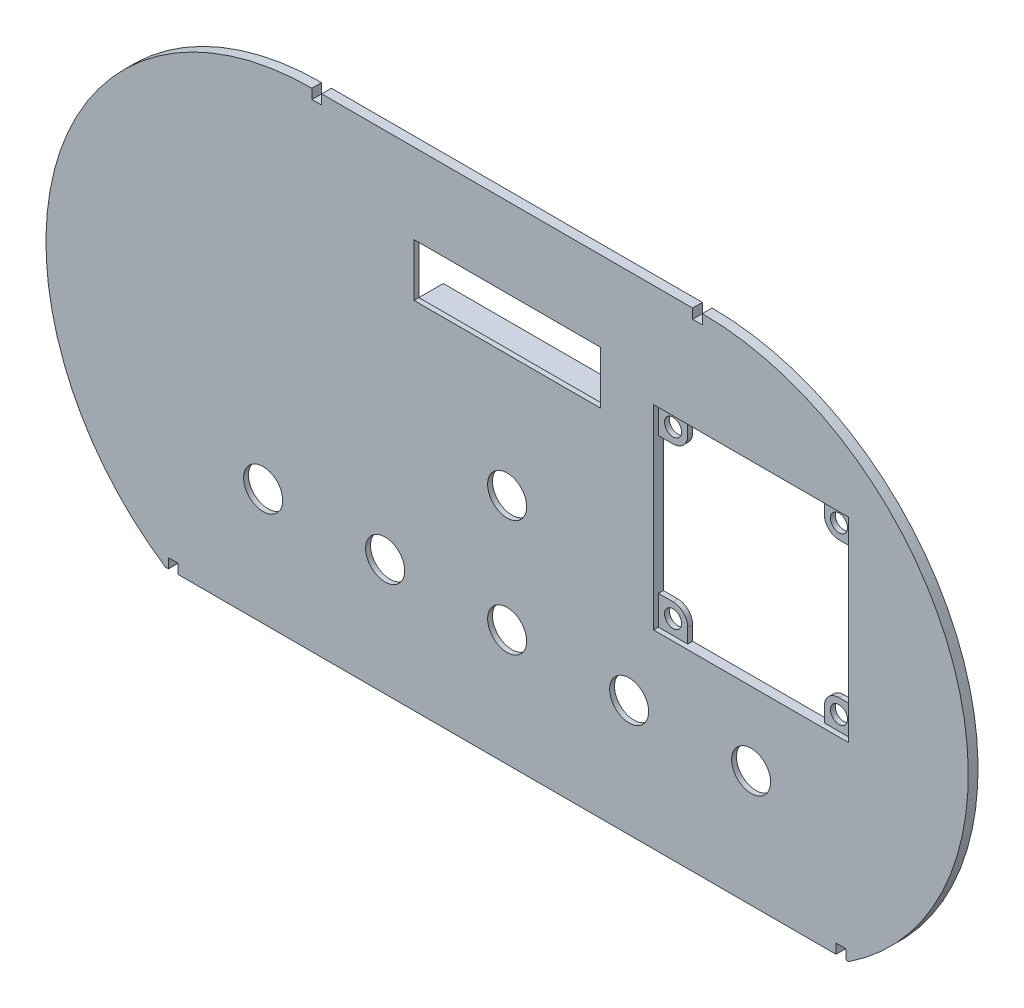
from build123d import *

# Parameters (mm, degrees)
BOSS_EXTRUDE1_DEPTH = 2
SKETCH2_W           = 40.18
SKETCH2_H           = 12.8
CUT_EXTRUDE1_DEPTH  = 1
SKETCH3_W           = 38.18
SKETCH3_H           = 10.8
CUT_EXTRUDE4_DEPTH  = 3
SKETCH4_W           = 2
SKETCH4_H           = 2
CUT_EXTRUDE5_DEPTH  = 3
SKETCH5_R           = 4
CUT_EXTRUDE6_DEPTH  = 5
SKETCH7_W           = 40.18
SKETCH7_H           = 2
BOSS_EXTRUDE2_DEPTH = 5
CUT_EXTRUDE10_DEPTH = 1
SKETCH12_W          = 40
SKETCH12_H          = 40
CUT_EXTRUDE11_DEPTH = 1
CUT_EXTRUDE12_REACH = 8
SKETCH13_R          = 1.75


with BuildPart() as part:
    # Sketch1 → Boss-Extrude1 (new body)
    with BuildSketch(Plane.XY):
        with BuildLine():
            Line((-70, -63.636363636), (70, -63.636363636))
            ThreePointArc((70, -63.636363636), (92.201532545, -2.475903873), (40, 36.363636364))
            Line((40, 36.363636364), (-40, 36.363636364))
            ThreePointArc((-40, 36.363636364), (-92.201532545, -2.475903873), (-70, -63.636363636))
        make_face()
    extrude(amount=BOSS_EXTRUDE1_DEPTH)

    # Sketch2 → Cut-Extrude1 (cut)
    with BuildSketch(Plane.XY):
        with Locations((0, 14.564946817)):
            Rectangle(SKETCH2_W, SKETCH2_H)
    extrude(amount=CUT_EXTRUDE1_DEPTH, mode=Mode.SUBTRACT)

    # Sketch3 → Cut-Extrude4 (cut, through all)
    with BuildSketch(Plane.XY):
        with Locations((0, 14.564946817)):
            Rectangle(SKETCH3_W, SKETCH3_H)
    extrude(amount=CUT_EXTRUDE4_DEPTH, mode=Mode.SUBTRACT)

    # Sketch4 → Cut-Extrude5 (cut, through all)
    with BuildSketch(Plane.XY.offset(2)):
        with Locations((-39, 35.363636364)):
            Rectangle(SKETCH4_W, SKETCH4_H)
        with Locations((39, 35.363636364)):
            Rectangle(SKETCH4_W, SKETCH4_H)
        with Locations((-68.39388, -62.636363636)):
            Rectangle(SKETCH4_W, SKETCH4_H)
        with Locations((68.39388, -62.636363636)):
            Rectangle(SKETCH4_W, SKETCH4_H)
    extrude(amount=-CUT_EXTRUDE5_DEPTH, mode=Mode.SUBTRACT)

    # Sketch5 → Cut-Extrude6 (cut)
    with BuildSketch(Plane.XY):
        with Locations((0, -15.909090909)):
            Circle(SKETCH5_R)
        with Locations((0, -39.772727273)):
            Circle(SKETCH5_R)
        with Locations((25, -39.772727273)):
            Circle(SKETCH5_R)
        with Locations((50, -39.772727273)):
            Circle(SKETCH5_R)
        with Locations((-25, -39.772727273)):
            Circle(SKETCH5_R)
        with Locations((-50, -39.772727273)):
            Circle(SKETCH5_R)
    extrude(amount=CUT_EXTRUDE6_DEPTH, mode=Mode.SUBTRACT)

    # Sketch7 → Boss-Extrude2 (add)
    with BuildSketch(Plane(origin=(0, 0, 0), x_dir=(-1, 0, 0), z_dir=(0, 0, -1))):
        with Locations((0, 7.164946817)):
            Rectangle(SKETCH7_W, SKETCH7_H)
    extrude(amount=BOSS_EXTRUDE2_DEPTH)

    # Sketch11 → Cut-Extrude10 (cut)
    with BuildSketch(Plane(origin=(0, 0, 0), x_dir=(-1, 0, 0), z_dir=(0, 0, -1))):
        Polygon((-60, -29.772727273), (-10, -29.772727273), (-10, -5.909090909), (10, -5.909090909), (10, -29.772727273), (60, -29.772727273), (60, -49.772727273), (-60, -49.772727273), align=None)
    extrude(amount=-CUT_EXTRUDE10_DEPTH, mode=Mode.SUBTRACT)

    # Sketch12 → Cut-Extrude11 (cut)
    with BuildSketch(Plane.XY.offset(2)):
        with Locations((50, -4.772727273)):
            Rectangle(SKETCH12_W, SKETCH12_H)
    extrude(amount=-CUT_EXTRUDE11_DEPTH, mode=Mode.SUBTRACT)

    # Sketch13 → Cut-Extrude12 (cut, up to next)
    with BuildSketch(Plane.XY.offset(1), mode=Mode.PRIVATE) as cut_extrude12_sk1:
        with Locations((33, 12.227272727)):
            Circle(SKETCH13_R)
    cut_extrude12_tool1 = extrude(cut_extrude12_sk1.sketch, amount=-CUT_EXTRUDE12_REACH, mode=Mode.PRIVATE) & part.part
    add(cut_extrude12_tool1.solids().sort_by_distance((33, 12.227273, 1))[0], mode=Mode.SUBTRACT)
    # Sketch13 → Cut-Extrude12 (cut, up to next)
    with BuildSketch(Plane.XY.offset(1), mode=Mode.PRIVATE) as cut_extrude12_sk2:
        with Locations((67, 12.227272727)):
            Circle(SKETCH13_R)
    cut_extrude12_tool2 = extrude(cut_extrude12_sk2.sketch, amount=-CUT_EXTRUDE12_REACH, mode=Mode.PRIVATE) & part.part
    add(cut_extrude12_tool2.solids().sort_by_distance((67, 12.227273, 1))[0], mode=Mode.SUBTRACT)
    # Sketch13 → Cut-Extrude12 (cut, up to next)
    with BuildSketch(Plane.XY.offset(1), mode=Mode.PRIVATE) as cut_extrude12_sk3:
        with Locations((33, -21.772727273)):
            Circle(SKETCH13_R)
    cut_extrude12_tool3 = extrude(cut_extrude12_sk3.sketch, amount=-CUT_EXTRUDE12_REACH, mode=Mode.PRIVATE) & part.part
    add(cut_extrude12_tool3.solids().sort_by_distance((33, -21.772727, 1))[0], mode=Mode.SUBTRACT)
    # Sketch13 → Cut-Extrude12 (cut, up to next)
    with BuildSketch(Plane.XY.offset(1), mode=Mode.PRIVATE) as cut_extrude12_sk4:
        with Locations((67, -21.772727273)):
            Circle(SKETCH13_R)
    cut_extrude12_tool4 = extrude(cut_extrude12_sk4.sketch, amount=-CUT_EXTRUDE12_REACH, mode=Mode.PRIVATE) & part.part
    add(cut_extrude12_tool4.solids().sort_by_distance((67, -21.772727, 1))[0], mode=Mode.SUBTRACT)
    # Sketch13 → Cut-Extrude12 (cut, up to next)
    with BuildSketch(Plane.XY.offset(1), mode=Mode.PRIVATE) as cut_extrude12_sk5:
        with BuildLine():
            Line((30, 9.227272727), (30, -18.772727273))
            Line((30, -18.772727273), (33, -18.772727273))
            ThreePointArc((33, -18.772727273), (35.121320344, -19.651406929), (36, -21.772727273))
            Line((36, -21.772727273), (36, -24.772727273))
            Line((36, -24.772727273), (64, -24.772727273))
            Line((64, -24.772727273), (64, -21.772727273))
            ThreePointArc((64, -21.772727273), (64.878679656, -19.651406929), (67, -18.772727273))
            Line((67, -18.772727273), (70, -18.772727273))
            Line((70, -18.772727273), (70, 9.227272727))
            Line((70, 9.227272727), (67, 9.227272727))
            ThreePointArc((67, 9.227272727), (64.878679656, 10.105952384), (64, 12.227272727))
            Line((64, 12.227272727), (64, 15.227272727))
            Line((64, 15.227272727), (36, 15.227272727))
            Line((36, 15.227272727), (36, 12.227272727))
            ThreePointArc((36, 12.227272727), (35.121320344, 10.105952384), (33, 9.227272727))
            Line((33, 9.227272727), (30, 9.227272727))
        make_face()
    cut_extrude12_tool5 = extrude(cut_extrude12_sk5.sketch, amount=-CUT_EXTRUDE12_REACH, mode=Mode.PRIVATE) & part.part
    add(cut_extrude12_tool5.solids().sort_by_distance((50, -4.772727, 1))[0], mode=Mode.SUBTRACT)


solid = part.part
